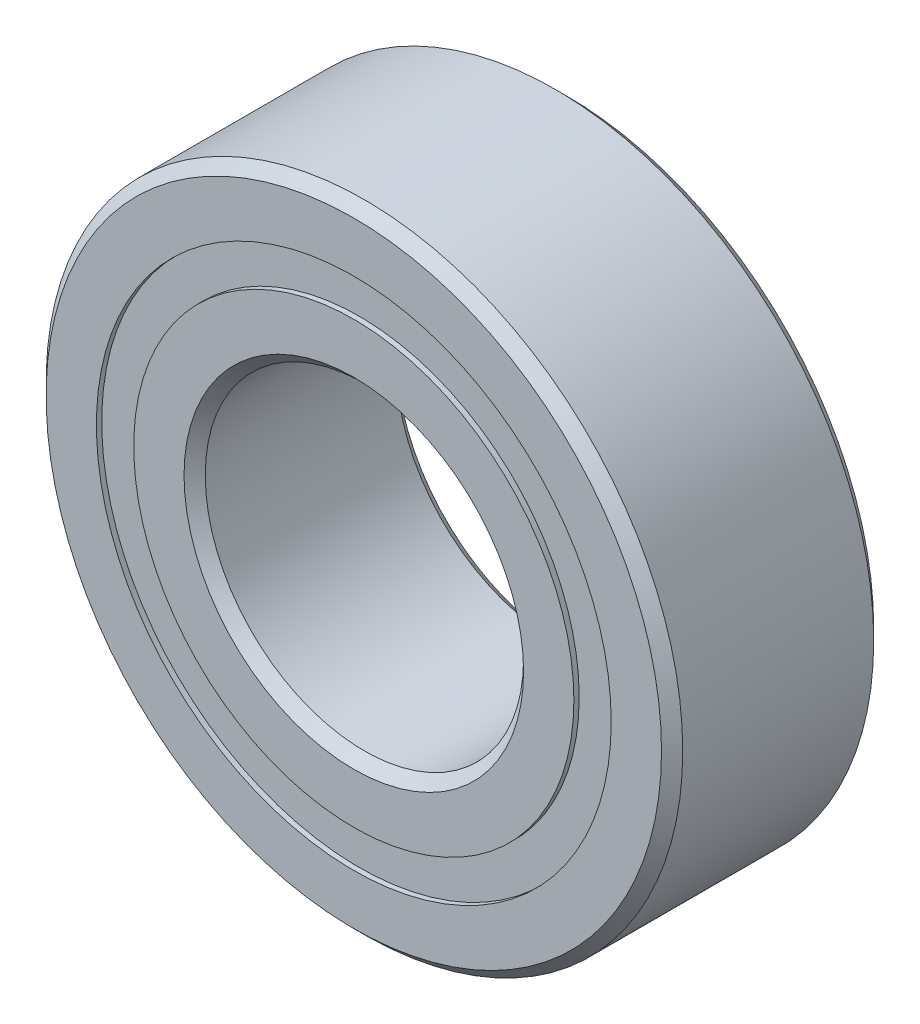
from build123d import *

# Parameters (mm, degrees)
CIRPATTERN1_COUNT = 12
SKETCH5_W         = 0.944081583
SKETCH5_H         = 0.703296704


with BuildPart() as part:
    # Sketch1 → Revolve1 (revolve)
    with BuildSketch(Plane(origin=(0, 0, 0), x_dir=(0, 0, -1), z_dir=(1, 0, 0))):
        with BuildLine():
            Line((1.8, 6), (-1.8, 6))
            Line((-1.8, 6), (-2, 5.8))
            Line((-2, 5.8), (-2, 4.851648352))
            Line((-2, 4.851648352), (-0.888888889, 4.851648352))
            ThreePointArc((-0.888888889, 4.851648352), (0, 5.455918417), (0.888888889, 4.851648352))
            Line((0.888888889, 4.851648352), (2, 4.851648352))
            Line((2, 4.851648352), (2, 5.8))
            Line((2, 5.8), (1.8, 6))
        make_face()
    revolve(axis=Axis((0, 0, 2), (0, 0, -1)))


with BuildPart() as body_2:
    # Sketch3 → Revolve3 (revolve)
    with BuildSketch(Plane(origin=(0, 0, 0), x_dir=(0, 0, -1), z_dir=(1, 0, 0))):
        with BuildLine():
            Line((-2, 4.148351648), (-0.888888889, 4.148351648))
            ThreePointArc((-0.888888889, 4.148351648), (0, 3.544081583), (0.888888889, 4.148351648))
            Line((0.888888889, 4.148351648), (2, 4.148351648))
            Line((2, 4.148351648), (2, 3.2))
            Line((2, 3.2), (1.8, 3))
            Line((1.8, 3), (-1.8, 3))
            Line((-1.8, 3), (-2, 3.2))
            Line((-2, 3.2), (-2, 4.148351648))
        make_face()
    revolve(axis=Axis((0, 0, 2), (0, 0, -1)))


with BuildPart() as body_3:
    # Sketch4 → Revolve4 (revolve)
    with BuildSketch(Plane(origin=(0, 0, 0), x_dir=(0, 0, -1), z_dir=(1, 0, 0))):
        with BuildLine():
            Line((-0.955918417, 4.5), (0.955918417, 4.5))
            ThreePointArc((0.955918417, 4.5), (0, 5.455918417), (-0.955918417, 4.5))
        make_face()
    revolve(axis=Axis((0, 4.5, 0.955918417), (0, 0, -1)))


with BuildPart() as cirpattern1_1:
    # CirPattern1: pattern copy
    add(body_3.part.rotate(Axis((0, 0, 0), (0, 0, 1)), 1 * 360 / CIRPATTERN1_COUNT))


with BuildPart() as cirpattern1_2:
    # CirPattern1: pattern copy
    add(body_3.part.rotate(Axis((0, 0, 0), (0, 0, 1)), 2 * 360 / CIRPATTERN1_COUNT))


with BuildPart() as cirpattern1_3:
    # CirPattern1: pattern copy
    add(body_3.part.rotate(Axis((0, 0, 0), (0, 0, 1)), 3 * 360 / CIRPATTERN1_COUNT))


with BuildPart() as cirpattern1_4:
    # CirPattern1: pattern copy
    add(body_3.part.rotate(Axis((0, 0, 0), (0, 0, 1)), 4 * 360 / CIRPATTERN1_COUNT))


with BuildPart() as cirpattern1_5:
    # CirPattern1: pattern copy
    add(body_3.part.rotate(Axis((0, 0, 0), (0, 0, 1)), 5 * 360 / CIRPATTERN1_COUNT))


with BuildPart() as cirpattern1_6:
    # CirPattern1: pattern copy
    add(body_3.part.rotate(Axis((0, 0, 0), (0, 0, 1)), 6 * 360 / CIRPATTERN1_COUNT))


with BuildPart() as cirpattern1_7:
    # CirPattern1: pattern copy
    add(body_3.part.rotate(Axis((0, 0, 0), (0, 0, 1)), 7 * 360 / CIRPATTERN1_COUNT))


with BuildPart() as cirpattern1_8:
    # CirPattern1: pattern copy
    add(body_3.part.rotate(Axis((0, 0, 0), (0, 0, 1)), 8 * 360 / CIRPATTERN1_COUNT))


with BuildPart() as cirpattern1_9:
    # CirPattern1: pattern copy
    add(body_3.part.rotate(Axis((0, 0, 0), (0, 0, 1)), 9 * 360 / CIRPATTERN1_COUNT))


with BuildPart() as cirpattern1_10:
    # CirPattern1: pattern copy
    add(body_3.part.rotate(Axis((0, 0, 0), (0, 0, 1)), 10 * 360 / CIRPATTERN1_COUNT))


with BuildPart() as cirpattern1_11:
    # CirPattern1: pattern copy
    add(body_3.part.rotate(Axis((0, 0, 0), (0, 0, 1)), 11 * 360 / CIRPATTERN1_COUNT))


with BuildPart() as body_15:
    # Sketch5 → Revolve5 (revolve)
    with BuildSketch(Plane(origin=(0, 0, 0), x_dir=(0, 0, -1), z_dir=(1, 0, 0))):
        with Locations((-1.427959209, 4.5)):
            Rectangle(SKETCH5_W, SKETCH5_H)
        with Locations((1.427959209, 4.5)):
            Rectangle(SKETCH5_W, SKETCH5_H)
    revolve(axis=Axis((0, 0, 2), (0, 0, -1)))


solid = Compound([part.part, body_2.part, body_3.part, cirpattern1_1.part, cirpattern1_2.part, cirpattern1_3.part, cirpattern1_4.part, cirpattern1_5.part, cirpattern1_6.part, cirpattern1_7.part, cirpattern1_8.part, cirpattern1_9.part, cirpattern1_10.part, cirpattern1_11.part, body_15.part])
